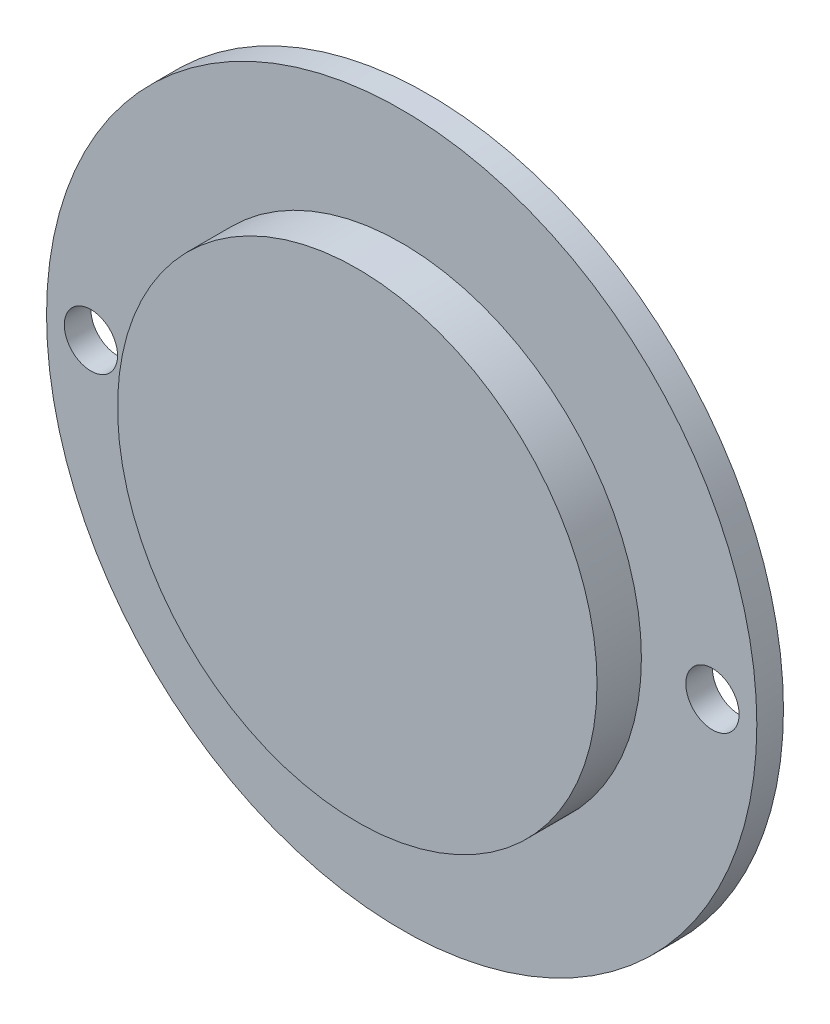
from build123d import *

# Parameters (mm, degrees)
SKETCH_1_R          = 40
EXTRUDE_1_DEPTH     = 3
SKETCH_2_R          = 27
EXTRUDE_2_DEPTH     = 5
SKETCH_3_R          = 3
CUT_EXTRUDE_1_DEPTH = 5


with BuildPart() as part:
    # 草图1 → 凸台-拉伸1 (new body)
    with BuildSketch(Plane.XY):
        Circle(SKETCH_1_R)
    extrude(amount=EXTRUDE_1_DEPTH)

    # 草图2 → 凸台-拉伸2 (add)
    with BuildSketch(Plane.XY.offset(3)):
        Circle(SKETCH_2_R)
    extrude(amount=EXTRUDE_2_DEPTH)

    # 草图3 → 切除-拉伸1 (cut)
    with BuildSketch(Plane(origin=(0, 0, 0), x_dir=(-1, 0, 0), z_dir=(0, 0, -1))):
        with Locations((35, 0)):
            Circle(SKETCH_3_R)
        with Locations((-35, 0)):
            Circle(SKETCH_3_R)
    extrude(amount=-CUT_EXTRUDE_1_DEPTH, mode=Mode.SUBTRACT)


solid = part.part
